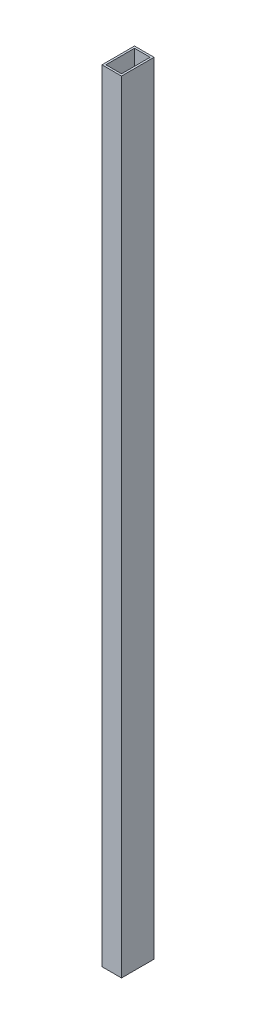
from build123d import *

# Parameters (mm, degrees)
SKETCH1_W           = 76.2
SKETCH1_H           = 127
SKETCH1_W_2         = 60.96
SKETCH1_H_2         = 111.76
BOSS_EXTRUDE1_DEPTH = 3048


with BuildPart() as part:
    # Sketch1 → Boss-Extrude1 (new body)
    with BuildSketch(Plane(origin=(0, 0, 0), x_dir=(1, 0, 0), z_dir=(0, 1, 0))):
        with Locations((38.1, 63.5)):
            Rectangle(SKETCH1_W, SKETCH1_H)
        with Locations((38.1, 63.5)):
            Rectangle(SKETCH1_W_2, SKETCH1_H_2, mode=Mode.SUBTRACT)
    extrude(amount=BOSS_EXTRUDE1_DEPTH)


solid = part.part
